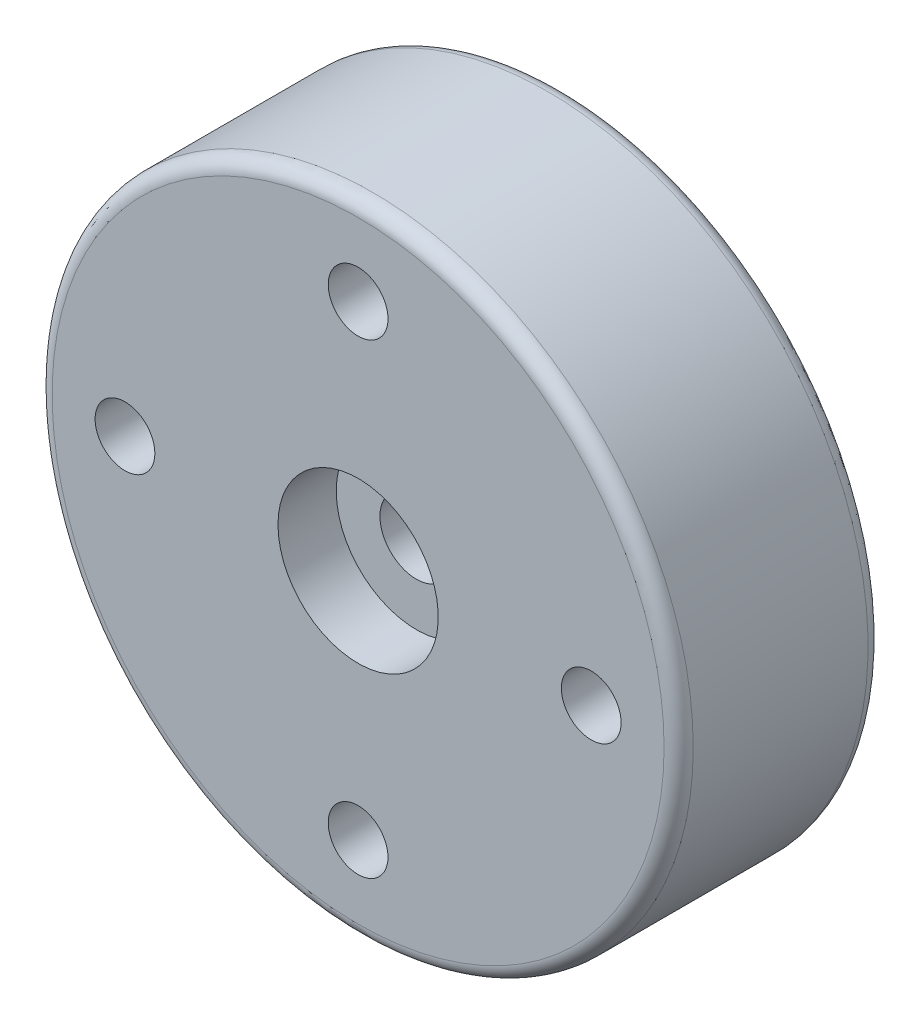
from build123d import *

# Parameters (mm, degrees)
M2_TAPPED_HOLE1_AT_2_COUNT = 2
M2_TAPPED_HOLE1_AT_2_PITCH = 11.313708499
M2_TAPPED_HOLE1_AT_3_COUNT = 2
M2_TAPPED_HOLE1_AT_3_PITCH = 16
M2_TAPPED_HOLE1_AT_4_COUNT = 2
M2_TAPPED_HOLE1_AT_4_PITCH = 11.313708499
M2_TAPPED_HOLE1_AT_5_COUNT = 2
M2_TAPPED_HOLE1_AT_5_PITCH = 8
RADYUS1_R                  = 0.5
IZIM1_R                    = 1.025
KES_EKSTR_ZYON1_DEPTH      = 10


with BuildPart() as part:
    # Sketch1 → Revolve1 (revolve)
    with BuildSketch(Plane(origin=(0, 0, 0), x_dir=(0, 0, -1), z_dir=(1, 0, 0))):
        Polygon((3.5, 1.25), (2, 1.25), (2, 2.75), (0, 2.75), (0, 11), (7, 11), (7, 2.75), (3.5, 2.75), align=None)
    revolve(axis=Axis((0, 0, 0), (0, 0, 1)))

    # Sketch4 → M2 Tapped Hole1 (revolve, cut)
    with BuildSketch(Plane(origin=(0, 8, 0), x_dir=(0, -1, 0), z_dir=(1, 0, 0))):
        Polygon((0, 0), (0, 7), (1.025, 7), (0.8, 6.870096189), (0.8, 0.129903811), (1.025, 0), align=None)
    m2_tapped_hole1 = revolve(axis=Axis((0, 8, 6.35), (0, 0, -1)), mode=Mode.SUBTRACT)

    # M2 Tapped Hole1 at 2: M2 Tapped Hole1 ×2
    with Locations(*[Vector(0.707106781, -0.707106781, 0) * (i * M2_TAPPED_HOLE1_AT_2_PITCH) for i in range(1, M2_TAPPED_HOLE1_AT_2_COUNT)]):
        add(m2_tapped_hole1, mode=Mode.SUBTRACT)

    # M2 Tapped Hole1 at 3: M2 Tapped Hole1 ×2
    with Locations(*[(0, -i * M2_TAPPED_HOLE1_AT_3_PITCH, 0) for i in range(1, M2_TAPPED_HOLE1_AT_3_COUNT)]):
        add(m2_tapped_hole1, mode=Mode.SUBTRACT)

    # M2 Tapped Hole1 at 4: M2 Tapped Hole1 ×2
    with Locations(*[Vector(-0.707106781, -0.707106781, 0) * (i * M2_TAPPED_HOLE1_AT_4_PITCH) for i in range(1, M2_TAPPED_HOLE1_AT_4_COUNT)]):
        add(m2_tapped_hole1, mode=Mode.SUBTRACT)

    # M2 Tapped Hole1 at 5: M2 Tapped Hole1 ×2
    with Locations(*[(0, -i * M2_TAPPED_HOLE1_AT_5_PITCH, 0) for i in range(1, M2_TAPPED_HOLE1_AT_5_COUNT)]):
        add(m2_tapped_hole1, mode=Mode.SUBTRACT)

    # Radyus1
    radyus1_edges = [part.edges().sort_by_distance(p)[0] for p in [
        (0, -11, -7),
        (0, -11, 0),
    ]]
    fillet(radyus1_edges, radius=RADYUS1_R)

    # Çizim1 → Kes-Ekstrüzyon1 (cut)
    with BuildSketch(Plane.XY):
        with Locations((0, 8)):
            Circle(IZIM1_R)
        with Locations((-8, 0)):
            Circle(IZIM1_R)
        with Locations((8, 0)):
            Circle(IZIM1_R)
        with Locations((0, -8)):
            Circle(IZIM1_R)
    extrude(amount=-KES_EKSTR_ZYON1_DEPTH, mode=Mode.SUBTRACT)


solid = part.part
